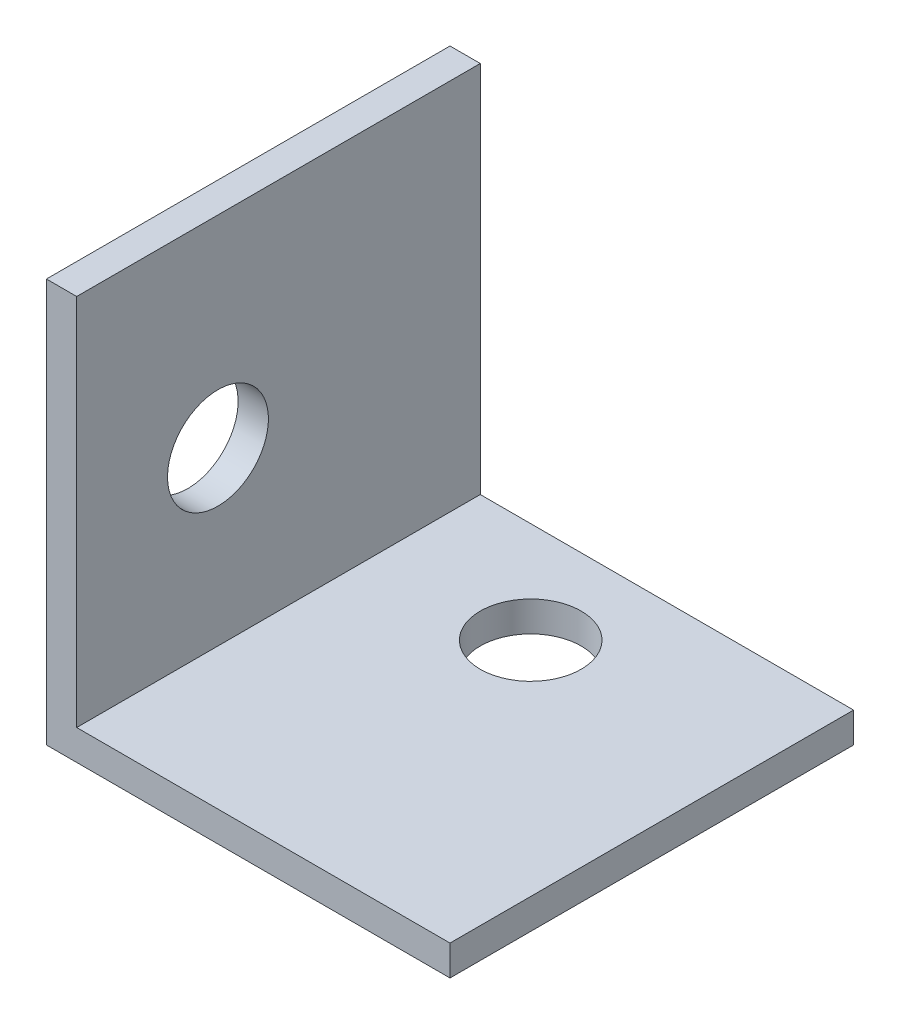
from build123d import *

# Parameters (mm, degrees)
EXTRUDE_THIN1_DEPTH = 20
SKETCH2_R           = 2.5
CUT_EXTRUDE1_DEPTH  = 35.641016151
SKETCH3_R           = 2.5
CUT_EXTRUDE2_DEPTH  = 34.797189232


with BuildPart() as part:
    # Sketch1 → Extrude-Thin1 (new body)
    with BuildSketch(Plane.XY):
        Polygon((0, 20), (0, 0), (20, 0), (20, 1.5), (1.5, 1.5), (1.5, 20), align=None)
    extrude(amount=EXTRUDE_THIN1_DEPTH)

    # Sketch2 → Cut-Extrude1 (cut, through all)
    with BuildSketch(Plane(origin=(0, 0, 0), x_dir=(-1, 0, 0), z_dir=(0, -1, 0))):
        with Locations((-9, -15)):
            Circle(SKETCH2_R)
    extrude(amount=-CUT_EXTRUDE1_DEPTH, mode=Mode.SUBTRACT)

    # Sketch3 → Cut-Extrude2 (cut, through all)
    with BuildSketch(Plane(origin=(1.5, 0, 0), x_dir=(0, 0, -1), z_dir=(1, 0, 0))):
        with Locations((-7, 10)):
            Circle(SKETCH3_R)
    extrude(amount=-CUT_EXTRUDE2_DEPTH, mode=Mode.SUBTRACT)


with BuildPart() as body_2:
    # Mirror1: mirrored copy
    add(part.part.mirror(Plane.XY))


solid = body_2.part
